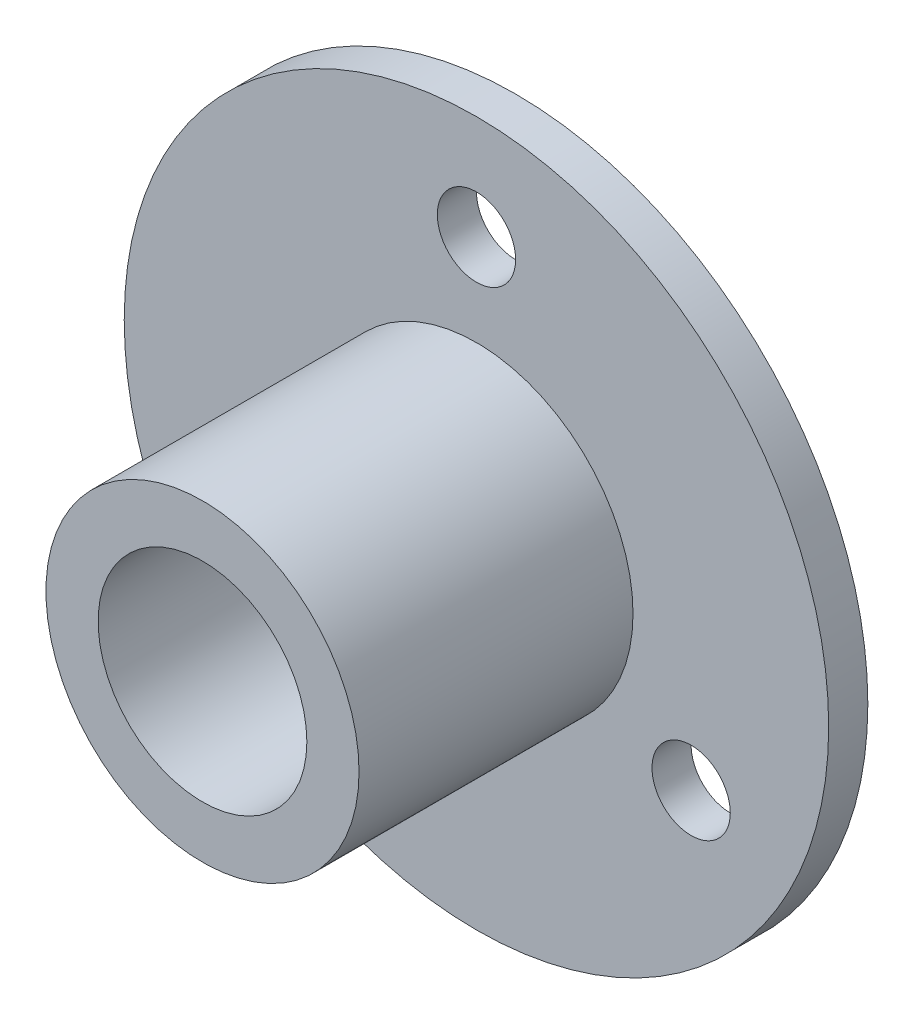
from build123d import *

# Parameters (mm, degrees)
SKETCH_1_R      = 13.5
SKETCH_1_R_2    = 1.5
SKETCH_1_R_3    = 4
EXTRUDE_1_DEPTH = 1.5
SKETCH_1_4_R    = 6
SKETCH_1_4_R_2  = 4
EXTRUDE_2_DEPTH = 12


with BuildPart() as part:
    # 草图1 → 凸台-拉伸1 (new body)
    with BuildSketch(Plane.XY):
        Circle(SKETCH_1_R)
        with Locations((-8.227241336, -4.75)):
            Circle(SKETCH_1_R_2, mode=Mode.SUBTRACT)
        with Locations((8.227241336, -4.75)):
            Circle(SKETCH_1_R_2, mode=Mode.SUBTRACT)
        with Locations((0, 9.5)):
            Circle(SKETCH_1_R_2, mode=Mode.SUBTRACT)
        Circle(SKETCH_1_R_3, mode=Mode.SUBTRACT)
    extrude(amount=EXTRUDE_1_DEPTH)

    # 草图1<4> → 凸台-拉伸2 (add)
    with BuildSketch(Plane.XY):
        Circle(SKETCH_1_4_R)
        Circle(SKETCH_1_4_R_2, mode=Mode.SUBTRACT)
    extrude(amount=EXTRUDE_2_DEPTH)


solid = part.part
